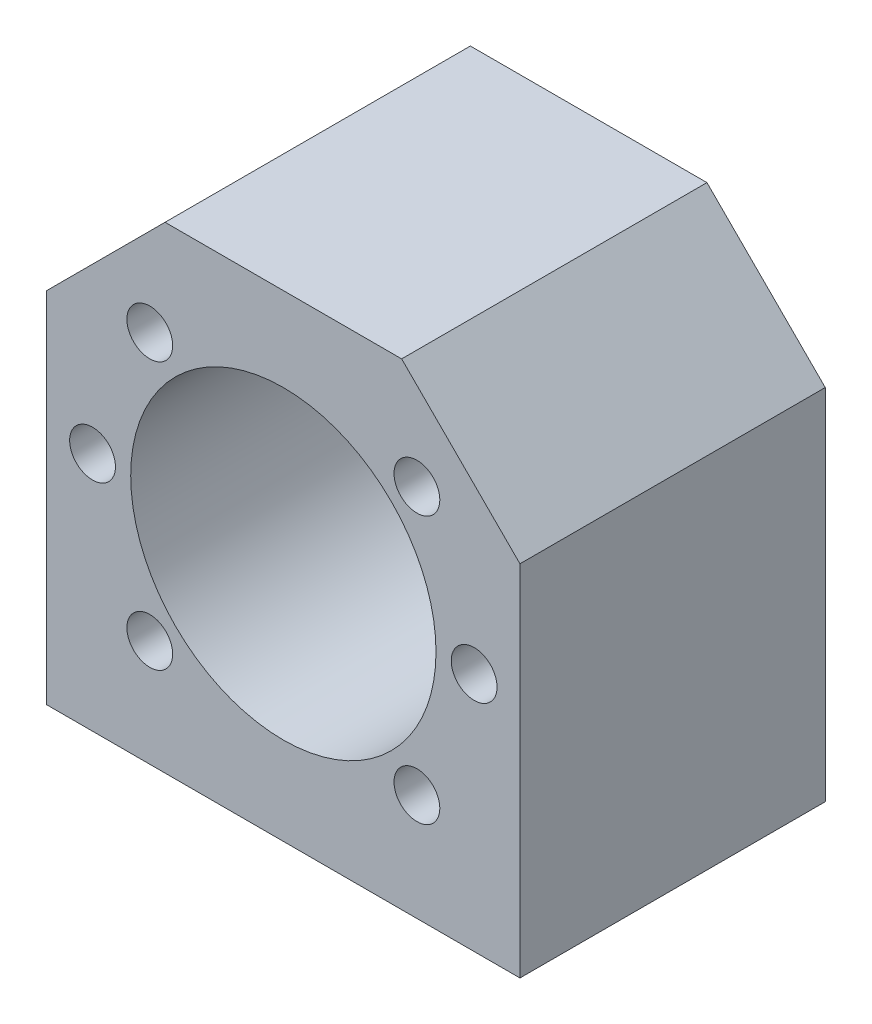
from build123d import *

# Parameters (mm, degrees)
DODANIE_WYCI_GNI_CIE1_DEPTH = 40
SZKIC2_R                    = 20
WYTNIJ_WYCI_GNI_CIE1_DEPTH  = 40
SZKIC4_R                    = 3
WYTNIJ_WYCI_GNI_CIE2_DEPTH  = 25
SZKIC5_R                    = 3
WYTNIJ_WYCI_GNI_CIE4_DEPTH  = 25


with BuildPart() as part:
    # Szkic1 → Dodanie-wyciągnięcie1 (new body)
    with BuildSketch(Plane.XY):
        Polygon((31, -31.5), (31, 15.5), (15.5, 31), (-15.5, 31), (-31, 15.5), (-31, -31.5), align=None)
    extrude(amount=DODANIE_WYCI_GNI_CIE1_DEPTH)

    # Szkic2 → Wytnij-wyciągnięcie1 (cut)
    with BuildSketch(Plane.XY.offset(40)):
        Circle(SZKIC2_R)
    extrude(amount=-WYTNIJ_WYCI_GNI_CIE1_DEPTH, mode=Mode.SUBTRACT)

    # Szkic4 → Wytnij-wyciągnięcie2 (cut)
    with BuildSketch(Plane.XY.offset(40)):
        with Locations((17.5, -17.5)):
            Circle(SZKIC4_R)
        with Locations((25, 0)):
            Circle(SZKIC4_R)
        with Locations((17.5, 17.5)):
            Circle(SZKIC4_R)
        with Locations((-25, 0)):
            Circle(SZKIC4_R)
        with Locations((-17.5, 17.5)):
            Circle(SZKIC4_R)
        with Locations((-17.5, -17.5)):
            Circle(SZKIC4_R)
    extrude(amount=-WYTNIJ_WYCI_GNI_CIE2_DEPTH, mode=Mode.SUBTRACT)

    # Szkic5 → Wytnij-wyciągnięcie4 (cut)
    with BuildSketch(Plane.XZ.offset(31.5)):
        with Locations((-26, 33)):
            Circle(SZKIC5_R)
        with Locations((-26, 7)):
            Circle(SZKIC5_R)
        with Locations((26, 33)):
            Circle(SZKIC5_R)
        with Locations((26, 7)):
            Circle(SZKIC5_R)
    extrude(amount=-WYTNIJ_WYCI_GNI_CIE4_DEPTH, mode=Mode.SUBTRACT)


solid = part.part
